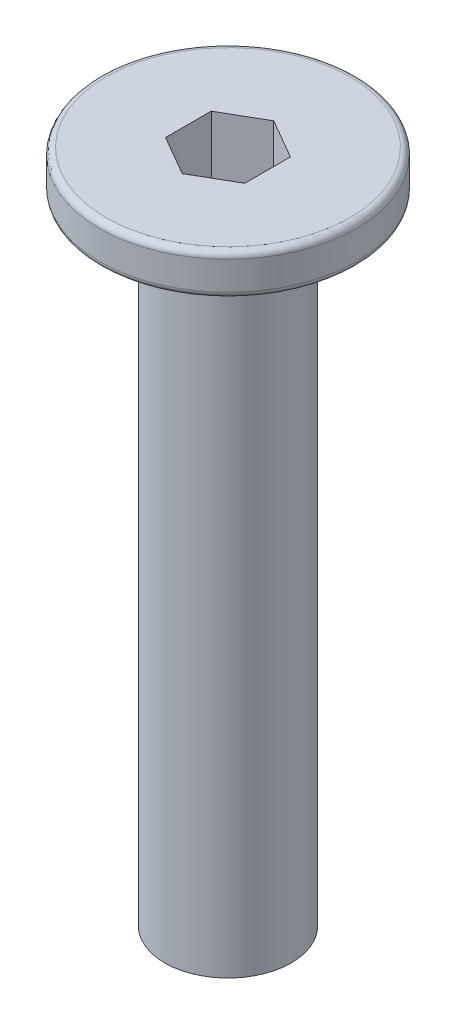
from build123d import *

# Parameters (mm, degrees)
SKETCH1_R           = 4.05
BOSS_EXTRUDE1_DEPTH = 1.3
FILLET1_R           = 0.2
SKETCH2_R           = 2
BOSS_EXTRUDE2_DEPTH = 20
CUT_EXTRUDE1_DEPTH  = 2


with BuildPart() as part:
    # Sketch1 → Boss-Extrude1 (new body)
    with BuildSketch(Plane(origin=(0, 0, 0), x_dir=(1, 0, 0), z_dir=(0, 1, 0))):
        Circle(SKETCH1_R)
    extrude(amount=BOSS_EXTRUDE1_DEPTH)

    # Fillet1
    fillet1_edges = [part.edges().sort_by_distance(p)[0] for p in [
        (-4.05, 0, 0),
        (-4.05, 1.3, 0),
    ]]
    fillet(fillet1_edges, radius=FILLET1_R)

    # Sketch2 → Boss-Extrude2 (add)
    with BuildSketch(Plane.XZ):
        Circle(SKETCH2_R)
    extrude(amount=BOSS_EXTRUDE2_DEPTH)

    # Sketch3 → Cut-Extrude1 (cut)
    with BuildSketch(Plane(origin=(0, 1.3, 0), x_dir=(1, 0, 0), z_dir=(0, 1, 0))):
        Polygon((-1.25, -0.721687836), (0, -1.443375673), (1.25, -0.721687836), (1.25, 0.721687836), (0, 1.443375673), (-1.25, 0.721687836), align=None)
    extrude(amount=-CUT_EXTRUDE1_DEPTH, mode=Mode.SUBTRACT)


solid = part.part
